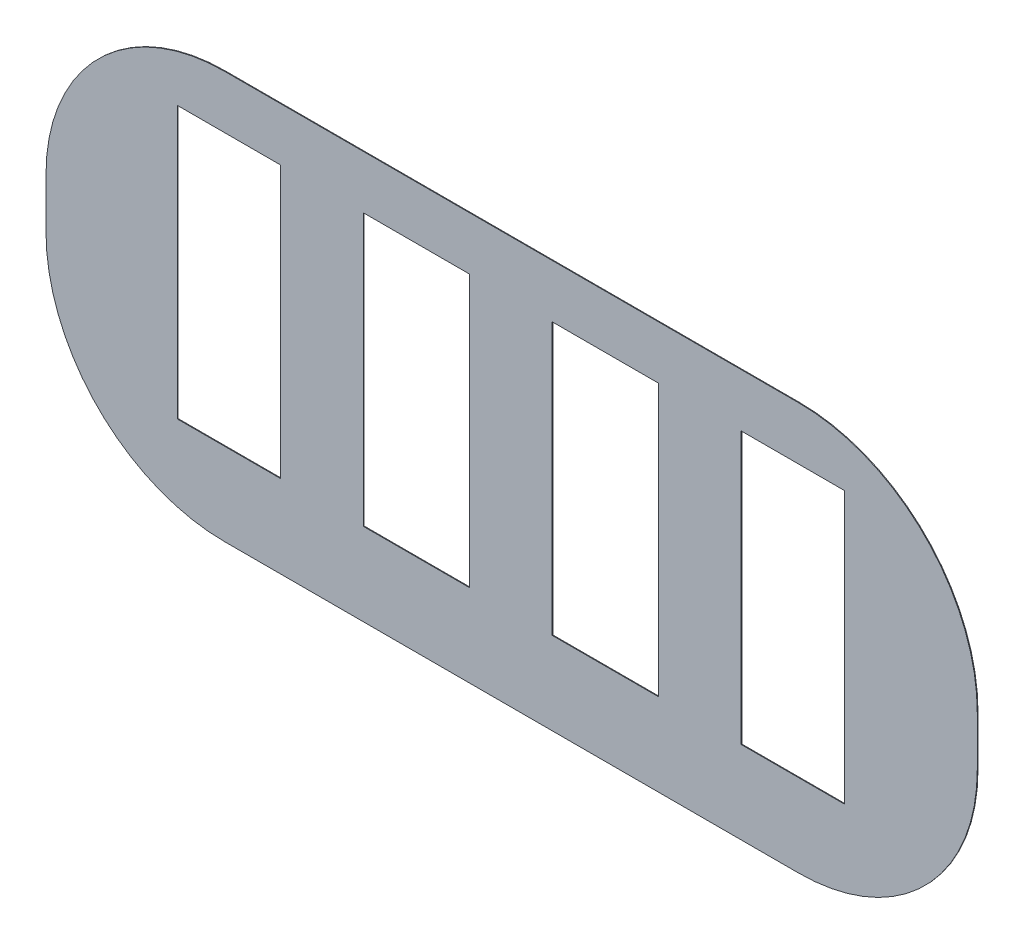
from build123d import *

# Parameters (mm, degrees)
BOSS_EXTRUDE1_DEPTH       = 0.0127
SKETCH2_W                 = 1.778
SKETCH2_H                 = 4.6736
CUT_EXTRUDE1_DEPTH        = 1.0127
LPATTERN1_COUNT           = 2
LPATTERN1_PITCH           = 3.2004
LPATTERN2_COUNT           = 3
LPATTERN2_PITCH           = 3.2512
LPATTERN2_COPY_1_SKETCH_W = 1.778
LPATTERN2_COPY_1_SKETCH_H = 4.6736
LPATTERN2_COPY_1_DEPTH    = 1.0127
LPATTERN2_COPY_2_SKETCH_W = 1.778
LPATTERN2_COPY_2_SKETCH_H = 4.6736
LPATTERN2_COPY_2_DEPTH    = 1.0127


with BuildPart() as part:
    # Sketch1 → Boss-Extrude1 (new body)
    with BuildSketch(Plane.XY):
        with BuildLine():
            Line((3.0734, 0), (12.954, 0))
            ThreePointArc((12.954, 0), (15.127221981, 0.900178019), (16.0274, 3.0734))
            Line((16.0274, 3.0734), (16.0274, 3.937))
            ThreePointArc((16.0274, 3.937), (15.127221981, 6.110221981), (12.954, 7.0104))
            Line((12.954, 7.0104), (3.0734, 7.0104))
            ThreePointArc((3.0734, 7.0104), (0.900178019, 6.110221981), (0, 3.937))
            Line((0, 3.937), (0, 3.0734))
            ThreePointArc((0, 3.0734), (0.900178019, 0.900178019), (3.0734, 0))
        make_face()
    extrude(amount=BOSS_EXTRUDE1_DEPTH)

    # Sketch2 → Cut-Extrude1 (cut, through all)
    with BuildSketch(Plane.XY.offset(0.0127)):
        with Locations((3.1496, 3.7592)):
            Rectangle(SKETCH2_W, SKETCH2_H)
    cut_extrude1 = extrude(amount=-CUT_EXTRUDE1_DEPTH, mode=Mode.SUBTRACT)

    # LPattern1: Cut-Extrude1 ×2
    with Locations(*[(i * LPATTERN1_PITCH, 0, 0) for i in range(1, LPATTERN1_COUNT)]):
        add(cut_extrude1, mode=Mode.SUBTRACT)

    # LPattern2: Cut-Extrude1 ×3
    with Locations(*[(i * LPATTERN2_PITCH, 0, 0) for i in range(1, LPATTERN2_COUNT)]):
        add(cut_extrude1, mode=Mode.SUBTRACT)

    # LPattern2 copy 1 sketch → LPattern2 copy 1 (cut, through all)
    with BuildSketch(Plane(origin=(6.4516, 0, 0.0127), x_dir=(1, 0, 0), z_dir=(0, 0, 1))):
        with Locations((3.1496, 3.7592)):
            Rectangle(LPATTERN2_COPY_1_SKETCH_W, LPATTERN2_COPY_1_SKETCH_H)
    extrude(amount=-LPATTERN2_COPY_1_DEPTH, mode=Mode.SUBTRACT)

    # LPattern2 copy 2 sketch → LPattern2 copy 2 (cut, through all)
    with BuildSketch(Plane(origin=(9.7028, 0, 0.0127), x_dir=(1, 0, 0), z_dir=(0, 0, 1))):
        with Locations((3.1496, 3.7592)):
            Rectangle(LPATTERN2_COPY_2_SKETCH_W, LPATTERN2_COPY_2_SKETCH_H)
    extrude(amount=-LPATTERN2_COPY_2_DEPTH, mode=Mode.SUBTRACT)


solid = part.part
